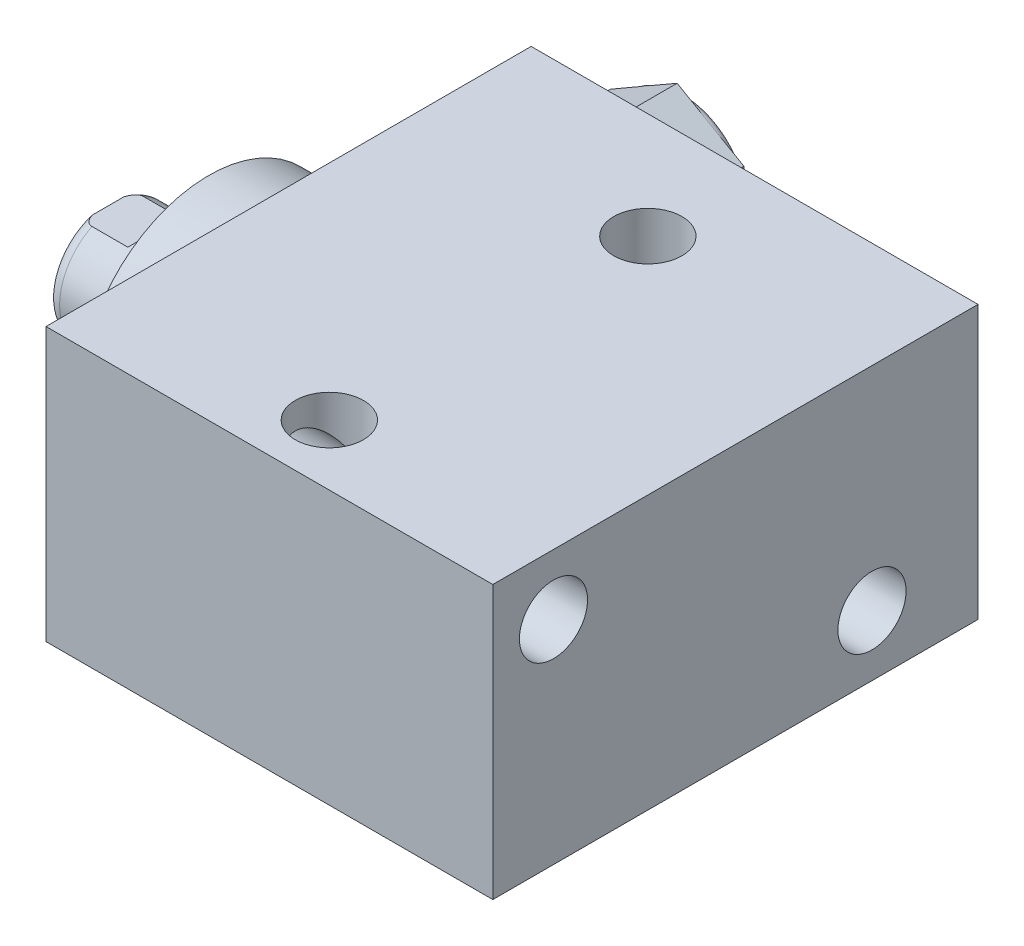
from build123d import *

# Parameters (mm, degrees)
SKETCH1_W          = 50.8
SKETCH1_H          = 28.575
EXTRUDE1_DEPTH     = 46.7868
LPATTERN1_COUNT    = 2
LPATTERN1_PITCH    = 27.94
SKETCH5_R          = 13.5001
EXTRUDE2_DEPTH     = 5.969
SKETCH6_W          = 6.3373
SKETCH6_H          = 10.541
CUT_EXTRUDE4_DEPTH = 30.48
HOLE1_D            = 7.137
HOLE1_DEPTH        = 46.7868
HOLE2_D            = 7.137
HOLE2_DEPTH        = 28.575
EXTRUDE3_DEPTH     = 6.779


with BuildPart() as part:
    # Sketch1 → Extrude1 (new body)
    with BuildSketch(Plane(origin=(0, 0, 0), x_dir=(0, 0, -1), z_dir=(1, 0, 0))):
        with Locations((2.3876, 0)):
            Rectangle(SKETCH1_W, SKETCH1_H)
    extrude(amount=EXTRUDE1_DEPTH)

    # S2D0002 → Cut-Revolve1 (revolve, cut)
    with BuildSketch(Plane(origin=(0, 4.7625, 0), x_dir=(-1, 0, 0), z_dir=(0, 1, 0)), mode=Mode.PRIVATE) as cut_revolve1_sk:
        Polygon((-14.5415, -27.5336), (-18.161, -27.5336), (-18.161, -27.7876), (-9.525, -27.7876), (-9.525, -14.0716), (-13.9446, -14.0716), (-13.9446, -26.9113), (-14.5415, -27.5082), align=None)
    cut_revolve1 = revolve(cut_revolve1_sk.sketch.rotate(Axis((9.525, 4.7625, -19.13842003), (0, 0, 1)), 180), axis=Axis((9.525, 4.7625, -19.13842003), (0, 0, 1)), mode=Mode.SUBTRACT)  # turned: the seam where the file's is

    # LPattern1: Cut-Revolve1 ×2
    with Locations(*[(i * LPATTERN1_PITCH, 0, 0) for i in range(1, LPATTERN1_COUNT)]):
        add(cut_revolve1, mode=Mode.SUBTRACT)

    # Sketch5 → Extrude2 (add)
    with BuildSketch(Plane.ZY):
        Circle(SKETCH5_R)
    extrude(amount=EXTRUDE2_DEPTH)

    # Sketch6 → Revolve1 (revolve)
    with BuildSketch(Plane(origin=(0, 0, 0), x_dir=(0, 0, 1), z_dir=(0, -1, 0)), mode=Mode.PRIVATE) as revolve1_sk:
        with Locations((-3.16865, 11.2395)):
            Rectangle(SKETCH6_W, SKETCH6_H)
    revolve(revolve1_sk.sketch.rotate(Axis((5.754582971, 0, 0), (-1, 0, 0)), 180), axis=Axis((5.754582971, 0, 0), (-1, 0, 0)))  # turned: the seam where the file's is

    # S2D0001 → Cut-Revolve4 (revolve, cut)
    with BuildSketch(Plane(origin=(-18.511260017, 3.2639, 0), x_dir=(0, 1, 0), z_dir=(0, 0, 1)), mode=Mode.PRIVATE) as cut_revolve4_sk:
        Polygon((-0.7493, -3.365076823), (-0.7493, -18.003260017), (-3.2639, -19.51418413), (-3.2639, -2.001260017), (0.0381, -2.001260017), align=None)
    revolve(cut_revolve4_sk.sketch.rotate(Axis((0, 0, 0), (-1, 0, 0)), 90), axis=Axis((0, 0, 0), (-1, 0, 0)), mode=Mode.SUBTRACT)  # turned: the seam where the file's is

    # Sketch8 → Cut-Revolve5 (revolve, cut)
    with BuildSketch(Plane(origin=(0, 0, 0), x_dir=(0, 0, -1), z_dir=(0, 1, 0)), mode=Mode.PRIVATE) as cut_revolve5_sk:
        with BuildLine():
            Line((-6.3373, 10.1854), (-6.096, 10.9474))
            Line((-6.096, 10.9474), (-6.096, 15.494))
            ThreePointArc((-6.096, 15.494), (-5.995678675, 16.037796865), (-5.707922533, 16.51))
            Line((-5.707922533, 16.51), (-6.3373, 16.51))
            Line((-6.3373, 16.51), (-6.3373, 10.1854))
        make_face()
    revolve(cut_revolve5_sk.sketch.rotate(Axis((-12.65936, 0, 0), (-1, 0, 0)), 180), axis=Axis((-12.65936, 0, 0), (-1, 0, 0)), mode=Mode.SUBTRACT)  # turned: the seam where the file's is

    # Sketch12 → Cut-Extrude4 (cut, symmetric)
    with BuildSketch(Plane(origin=(0, 0, 0), x_dir=(0, -1, 0), z_dir=(0, 0, -1))):
        Polygon((5.461, 16.51), (5.461, 11.7348), (6.096, 11.0998), (6.096, 16.51), align=None)
        Polygon((-5.461, 16.51), (-5.461, 11.7348), (-6.096, 11.0998), (-6.096, 16.51), align=None)
    extrude(amount=CUT_EXTRUDE4_DEPTH, both=True, mode=Mode.SUBTRACT)

    # Hole1
    with Locations(Plane.ZY):
        with Locations((-16.6878, -7.9248), (16.6624, 7.9502)):
            Hole(HOLE1_D / 2, depth=HOLE1_DEPTH)

    # Hole2
    with Locations(Plane(origin=(0, 14.2875, 0), x_dir=(-1, 0, 0), z_dir=(0, 1, 0))):
        with Locations((-23.3172, -16.6878), (-23.3172, 16.6624)):
            Hole(HOLE2_D / 2, depth=HOLE2_DEPTH)

    # Sketch18 → Extrude3 (add)
    with BuildSketch(Plane(origin=(0, 0, -27.5336), x_dir=(-1, 0, 0), z_dir=(0, 0, -1))):
        Polygon((-2.54, 8.79529163), (-9.525, 12.828083261), (-16.51, 8.79529163), (-16.51, 0.72970837), (-9.525, -3.303083261), (-2.54, 0.72970837), align=None)
    extrude(amount=EXTRUDE3_DEPTH)

    # Sketch19 → Cut-Revolve6 (revolve, cut)
    with BuildSketch(Plane(origin=(0, 4.7625, 0), x_dir=(-1, 0, 0), z_dir=(0, 1, 0)), mode=Mode.PRIVATE) as cut_revolve6_sk:
        with BuildLine():
            Line((-15.748, -34.3126), (-15.748, -36.7256))
            Line((-15.748, -36.7256), (-18.923, -36.7256))
            Line((-18.923, -36.7256), (-18.923, -33.5506))
            Line((-18.923, -33.5506), (-16.51, -33.5506))
            ThreePointArc((-16.51, -33.5506), (-16.286815367, -34.089415367), (-15.748, -34.3126))
        make_face()
    revolve(cut_revolve6_sk.sketch.rotate(Axis((9.525, 4.7625, -18.51025594), (0, 0, -1)), 180), axis=Axis((9.525, 4.7625, -18.51025594), (0, 0, -1)), mode=Mode.SUBTRACT)  # turned: the seam where the file's is


solid = part.part
